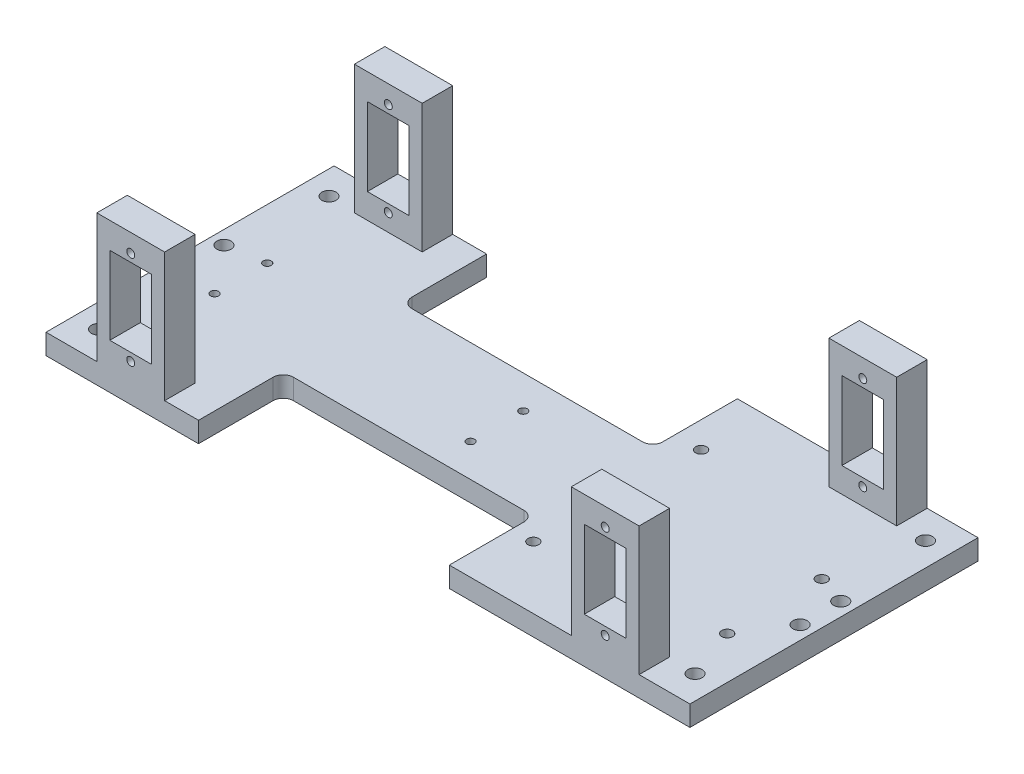
from build123d import *

# Parameters (mm, degrees)
SKETCH1_W               = 190
SKETCH1_H               = 85
BOSS_EXTRUDE1_DEPTH     = 6
SKETCH2_W               = 20
SKETCH2_H               = 9
BOSS_EXTRUDE2_DEPTH     = 38
SKETCH3_R               = 1.175
SKETCH3_W               = 12.35
SKETCH3_H               = 23
CUT_EXTRUDE1_DEPTH      = 30
MIRROR2_COPY_1_SKETCH_W = 20
MIRROR2_COPY_1_SKETCH_H = 9
MIRROR2_COPY_1_DEPTH    = 38
MIRROR2_COPY_2_SKETCH_R = 1.175
MIRROR2_COPY_2_SKETCH_W = 12.35
MIRROR2_COPY_2_SKETCH_H = 23
MIRROR2_COPY_2_DEPTH    = 30
SKETCH10_R              = 1.6
CUT_EXTRUDE2_DEPTH      = 6
SKETCH11_R              = 2.1
CUT_EXTRUDE3_DEPTH      = 10
SKETCH15_W              = 74
SKETCH15_H              = 25
CUT_EXTRUDE5_DEPTH      = 10
FILLET3_R               = 3
SKETCH16_R              = 2.1
CUT_EXTRUDE6_DEPTH      = 10
SKETCH13_R              = 1.175
CUT_EXTRUDE7_DEPTH      = 10


with BuildPart() as part:
    # Sketch1 → Boss-Extrude1 (new body)
    with BuildSketch(Plane(origin=(0, 0, 0), x_dir=(1, 0, 0), z_dir=(0, 1, 0))):
        Rectangle(SKETCH1_W, SKETCH1_H)
    extrude(amount=BOSS_EXTRUDE1_DEPTH)

    # Sketch2 → Boss-Extrude2 (add)
    with BuildSketch(Plane(origin=(0, 6, 0), x_dir=(1, 0, 0), z_dir=(0, 1, 0))):
        with Locations((70, -38)):
            Rectangle(SKETCH2_W, SKETCH2_H)
    boss_extrude2 = extrude(amount=BOSS_EXTRUDE2_DEPTH)

    # Sketch3 → Cut-Extrude1 (cut)
    with BuildSketch(Plane.XY.offset(42.5)):
        with Locations((70, 38.67)):
            Circle(SKETCH3_R)
        with Locations((70, 11.03)):
            Circle(SKETCH3_R)
        with Locations((70, 24.85)):
            Rectangle(SKETCH3_W, SKETCH3_H)
    cut_extrude1 = extrude(amount=-CUT_EXTRUDE1_DEPTH, mode=Mode.SUBTRACT)

    # Mirror1: Boss-Extrude2, Cut-Extrude1 across plane
    add(boss_extrude2.mirror(Plane.XY))
    add(cut_extrude1.mirror(Plane.XY), mode=Mode.SUBTRACT)

    # Mirror2: Boss-Extrude2, Cut-Extrude1 across plane
    add(boss_extrude2.mirror(Plane.ZY))
    add(cut_extrude1.mirror(Plane.ZY), mode=Mode.SUBTRACT)

    # Mirror2 copy 1 sketch → Mirror2 copy 1 (add)
    with BuildSketch(Plane(origin=(0, 6, 0), x_dir=(-1, 0, 0), z_dir=(0, 1, 0))):
        with Locations((70, -38)):
            Rectangle(MIRROR2_COPY_1_SKETCH_W, MIRROR2_COPY_1_SKETCH_H)
    extrude(amount=MIRROR2_COPY_1_DEPTH)

    # Mirror2 copy 2 sketch → Mirror2 copy 2 (cut)
    with BuildSketch(Plane(origin=(0, 0, -42.5), x_dir=(-1, 0, 0), z_dir=(0, 0, -1))):
        with Locations((70, 38.67)):
            Circle(MIRROR2_COPY_2_SKETCH_R)
        with Locations((70, 11.03)):
            Circle(MIRROR2_COPY_2_SKETCH_R)
        with Locations((70, 24.85)):
            Rectangle(MIRROR2_COPY_2_SKETCH_W, MIRROR2_COPY_2_SKETCH_H)
    extrude(amount=-MIRROR2_COPY_2_DEPTH, mode=Mode.SUBTRACT)

    # Sketch10 → Cut-Extrude2 (cut)
    with BuildSketch(Plane(origin=(0, 6, 0), x_dir=(1, 0, 0), z_dir=(0, 1, 0))):
        with Locations(Location((31.7, 24.1, 0), (0, 0, 270))):
            Circle(SKETCH10_R)
        with Locations(Location((82.5, 8.9, 0), (0, 0, 270))):
            Circle(SKETCH10_R)
        with Locations(Location((82.5, -19, 0), (0, 0, 270))):
            Circle(SKETCH10_R)
        with Locations(Location((30.4, -24.1, 0), (0, 0, 270))):
            Circle(SKETCH10_R)
    extrude(amount=-CUT_EXTRUDE2_DEPTH, mode=Mode.SUBTRACT)

    # Sketch11 → Cut-Extrude3 (cut)
    with BuildSketch(Plane(origin=(0, 6, 0), x_dir=(1, 0, 0), z_dir=(0, 1, 0))):
        with Locations(Location((88, 34, 0), (0, 0, 270))):
            Circle(SKETCH11_R)
        with Locations(Location((88, -34, 0), (0, 0, 270))):
            Circle(SKETCH11_R)
        with Locations(Location((-88, 34, 0), (0, 0, 270))):
            Circle(SKETCH11_R)
        with Locations(Location((-88, -34, 0), (0, 0, 270))):
            Circle(SKETCH11_R)
    extrude(amount=-CUT_EXTRUDE3_DEPTH, mode=Mode.SUBTRACT)

    # Sketch15 → Cut-Extrude5 (cut)
    with BuildSketch(Plane(origin=(0, 6, 0), x_dir=(1, 0, 0), z_dir=(0, 1, 0))):
        with Locations((-13, 30)):
            Rectangle(SKETCH15_W, SKETCH15_H)
        with Locations((-13, -30)):
            Rectangle(SKETCH15_W, SKETCH15_H)
    extrude(amount=-CUT_EXTRUDE5_DEPTH, mode=Mode.SUBTRACT)

    # Fillet3
    fillet3_edges = [part.edges().sort_by_distance(p)[0] for p in [
        (-50, 3, -17.5),
        (24, 3, -17.5),
        (-50, 3, 17.5),
        (24, 3, 17.5),
    ]]
    fillet(fillet3_edges, radius=FILLET3_R)

    # Sketch16 → Cut-Extrude6 (cut)
    with BuildSketch(Plane(origin=(0, 6, 0), x_dir=(1, 0, 0), z_dir=(0, 1, 0))):
        with Locations(Location((91, 6, 0), (0, 0, 270))):
            Circle(SKETCH16_R)
        with Locations(Location((91, -6, 0), (0, 0, 270))):
            Circle(SKETCH16_R)
        with Locations(Location((-91, 6, 0), (0, 0, 270))):
            Circle(SKETCH16_R)
        with Locations(Location((-91, -6, 0), (0, 0, 270))):
            Circle(SKETCH16_R)
    extrude(amount=-CUT_EXTRUDE6_DEPTH, mode=Mode.SUBTRACT)

    # Sketch13 → Cut-Extrude7 (cut)
    with BuildSketch(Plane(origin=(0, 6, 0), x_dir=(1, 0, 0), z_dir=(0, 1, 0))):
        with Locations(Location((-4.45, 7.775, 0), (0, 0, 270))):
            Circle(SKETCH13_R)
        with Locations(Location((-4.45, -7.775, 0), (0, 0, 270))):
            Circle(SKETCH13_R)
        with Locations(Location((-80, 7.775, 0), (0, 0, 270))):
            Circle(SKETCH13_R)
        with Locations(Location((-80, -7.775, 0), (0, 0, 270))):
            Circle(SKETCH13_R)
    extrude(amount=-CUT_EXTRUDE7_DEPTH, mode=Mode.SUBTRACT)


solid = part.part
